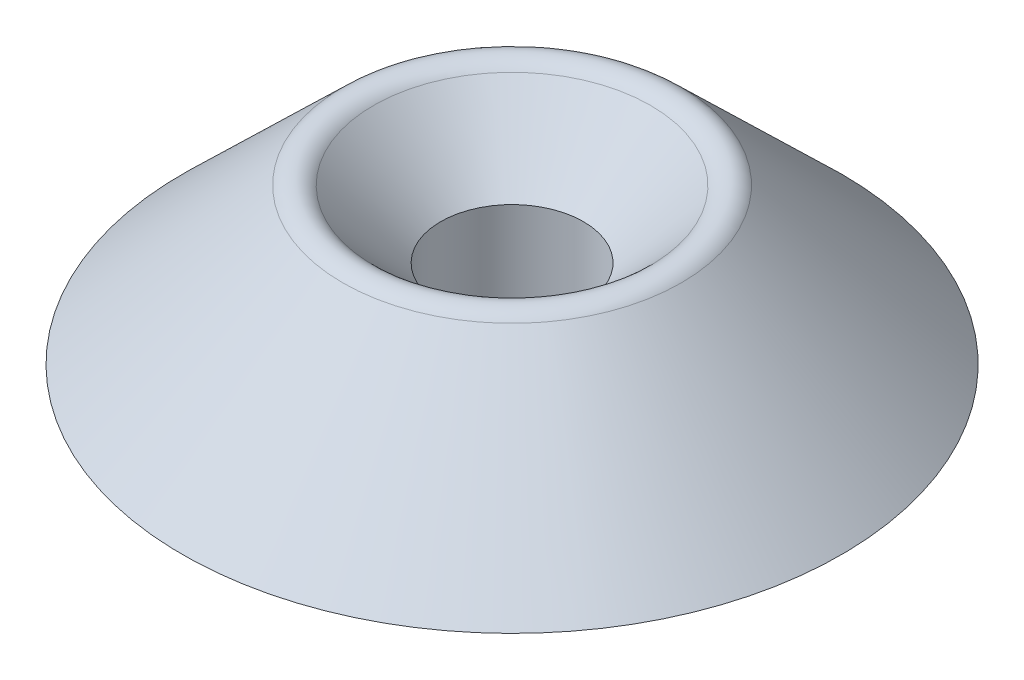
from build123d import *

# Parameters (mm, degrees)
CONG_1_R = 1


with BuildPart() as part:
    # Esquisse1 → Révolution1 (revolve)
    with BuildSketch(Plane.XY):
        Polygon((3.25, 0), (15, 0), (7, 7.75), (3.25, 4), align=None)
    revolve(axis=Axis((0, 0, 0), (0, 1, 0)))

    # Congé1
    cong_1_edges = [part.edges().sort_by_distance(p)[0] for p in [
        (-7, 7.75, 0),
    ]]
    fillet(cong_1_edges, radius=CONG_1_R)


solid = part.part
